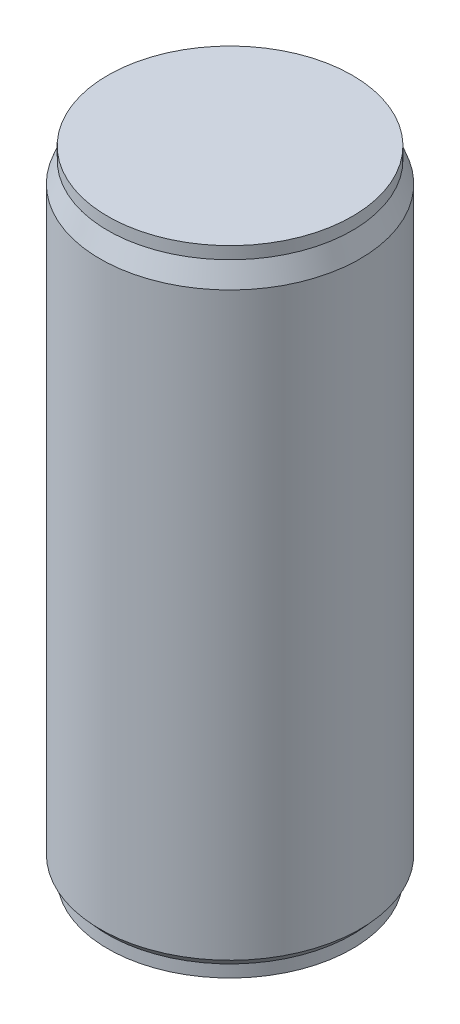
from build123d import *


with BuildPart() as part:
    # Sketch1 → Revolve1 (revolve)
    with BuildSketch(Plane.XY):
        Polygon((0, 0), (0, 131.7625), (25.4, 131.7625), (25.4, 129.2225), (26.9875, 124.9045), (26.9875, 4.318), (25.4, 2.54), (25.4, 0), align=None)
    revolve(axis=Axis((0, 0, 0), (0, 1, 0)))


solid = part.part
